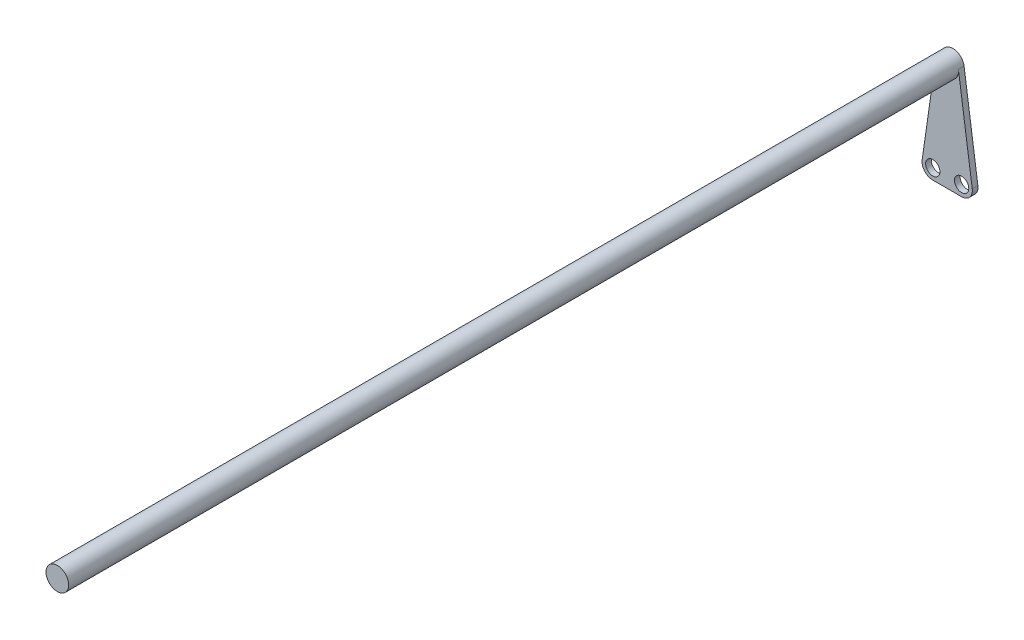
from build123d import *

# Parameters (mm, degrees)
SKETCH1_R           = 6.35
BOSS_EXTRUDE1_DEPTH = 250
BOSS_EXTRUDE2_DEPTH = 1.5875
CUT_EXTRUDE1_REACH  = 5.175
SKETCH3_R           = 4


with BuildPart() as part:
    # Sketch1 → Boss-Extrude1 (new body, symmetric)
    with BuildSketch(Plane.XY):
        Circle(SKETCH1_R)
    extrude(amount=BOSS_EXTRUDE1_DEPTH, both=True)

    # Sketch2 → Boss-Extrude2 (add, symmetric)
    with BuildSketch(Plane(origin=(0, 0, -250), x_dir=(-1, 0, 0), z_dir=(0, 0, -1))):
        with BuildLine():
            Line((-6.285975, 0.899452), (-14.01986, -53.150124))
            ThreePointArc((-14.01986, -53.150124), (-12.613526, -57.930696), (-8.080356, -60))
            Line((-8.080356, -60), (8.080356, -60))
            ThreePointArc((8.080356, -60), (12.613526, -57.930696), (14.01986, -53.150124))
            Line((14.01986, -53.150124), (6.285975, 0.899452))
            ThreePointArc((6.285975, 0.899452), (0, 6.35), (-6.285975, 0.899452))
        make_face()
    extrude(amount=BOSS_EXTRUDE2_DEPTH, both=True)

    # Sketch3 → Cut-Extrude1 (cut, up to next)
    with BuildSketch(Plane.XY.offset(-248.4125), mode=Mode.PRIVATE) as cut_extrude1_sk1:
        with Locations((-8.080356, -54)):
            Circle(SKETCH3_R)
    cut_extrude1_tool1 = extrude(cut_extrude1_sk1.sketch, amount=-CUT_EXTRUDE1_REACH, mode=Mode.PRIVATE) & part.part
    add(cut_extrude1_tool1.solids().sort_by_distance((-8.080356, -54, -248.4125))[0], mode=Mode.SUBTRACT)
    # Sketch3 → Cut-Extrude1 (cut, up to next)
    with BuildSketch(Plane.XY.offset(-248.4125), mode=Mode.PRIVATE) as cut_extrude1_sk2:
        with Locations((8.080356, -54)):
            Circle(SKETCH3_R)
    cut_extrude1_tool2 = extrude(cut_extrude1_sk2.sketch, amount=-CUT_EXTRUDE1_REACH, mode=Mode.PRIVATE) & part.part
    add(cut_extrude1_tool2.solids().sort_by_distance((8.080356, -54, -248.4125))[0], mode=Mode.SUBTRACT)


solid = part.part
